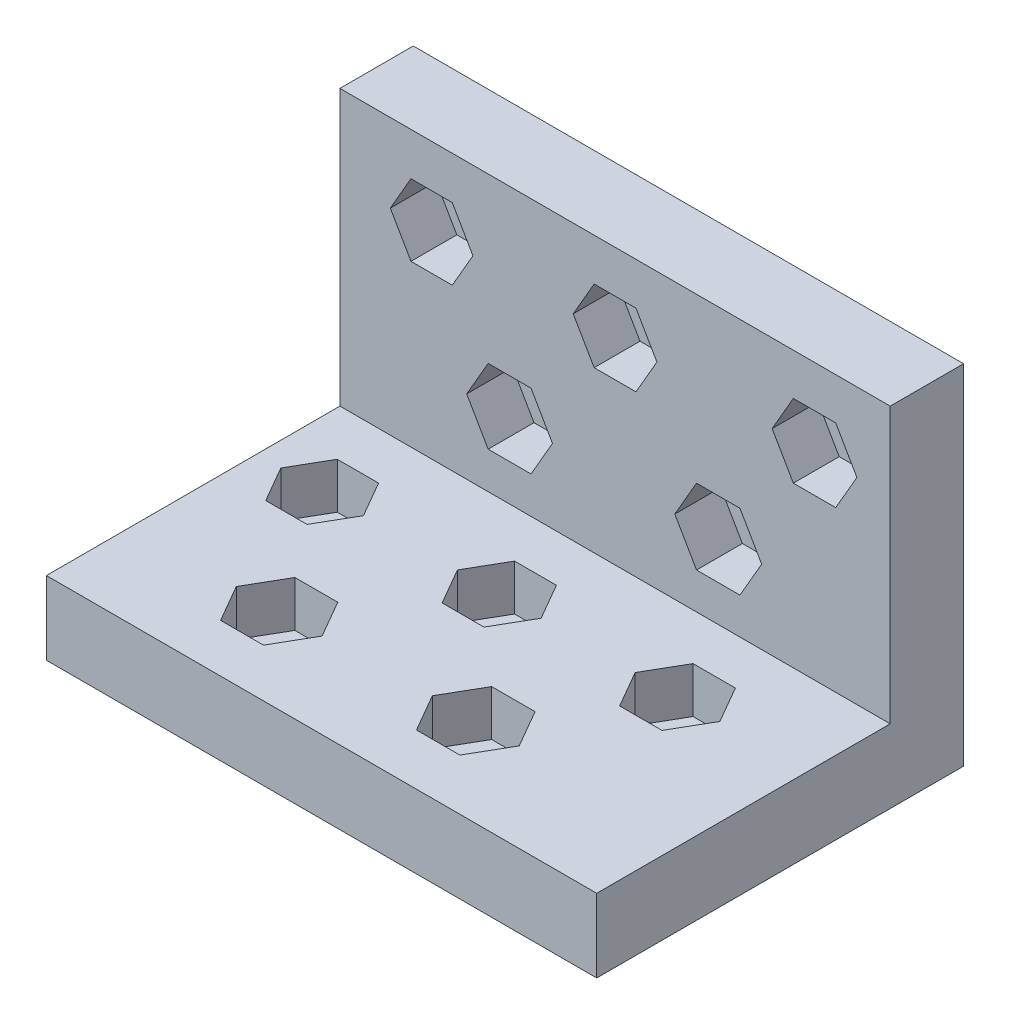
from build123d import *

# Parameters (mm, degrees)
SKETCH1_W               = 30
SKETCH1_H               = 20
BOSS_EXTRUDE1_DEPTH     = 4
SKETCH2_W               = 30
SKETCH2_H               = 4
BOSS_EXTRUDE2_DEPTH     = 15
CUT_EXTRUDE1_DEPTH      = 2.5
SKETCH4_R               = 1
CUT_EXTRUDE2_DEPTH      = 19.5
CUT_EXTRUDE2_DEPTH_BACK = 2.5
CUT_EXTRUDE3_DEPTH      = 16
CUT_EXTRUDE3_DEPTH_BACK = 2.5
SKETCH6_R               = 1
CUT_EXTRUDE4_DEPTH      = 18.5
CUT_EXTRUDE4_DEPTH_BACK = 2.5


with BuildPart() as part:
    # Sketch1 → Boss-Extrude1 (new body)
    with BuildSketch(Plane(origin=(0, 0, 0), x_dir=(1, 0, 0), z_dir=(0, 1, 0))):
        Rectangle(SKETCH1_W, SKETCH1_H)
    extrude(amount=BOSS_EXTRUDE1_DEPTH)

    # Sketch2 → Boss-Extrude2 (add)
    with BuildSketch(Plane(origin=(0, 4, 0), x_dir=(1, 0, 0), z_dir=(0, 1, 0))):
        with Locations((0, 8)):
            Rectangle(SKETCH2_W, SKETCH2_H)
    extrude(amount=BOSS_EXTRUDE2_DEPTH)

    # Sketch3 → Cut-Extrude1 (cut)
    with BuildSketch(Plane.XY.offset(-6)):
        Polygon((-8.874166975, 12.771236672), (-7.74833395, 14.721236672), (-8.874166975, 16.671236672), (-11.125833025, 16.671236672), (-12.25166605, 14.721236672), (-11.125833025, 12.771236672), align=None)
        Polygon((1.140266782, 12.743045001), (2.280533563, 14.718045001), (1.140266782, 16.693045001), (-1.140266782, 16.693045001), (-2.280533563, 14.718045001), (-1.140266782, 12.743045001), align=None)
        Polygon((12.028231439, 12.721236672), (13.182931977, 14.721236672), (12.028231439, 16.721236672), (9.718830362, 16.721236672), (8.564129823, 14.721236672), (9.718830362, 12.721236672), align=None)
        Polygon((-4.580088939, 6.006448413), (-3.410954644, 8.031448413), (-4.580088939, 10.056448413), (-6.91835753, 10.056448413), (-8.087491825, 8.031448413), (-6.91835753, 6.006448413), align=None)
        Polygon((6.807808173, 5.981448413), (7.991376224, 8.031448413), (6.807808173, 10.081448413), (4.440672069, 10.081448413), (3.257104017, 8.031448413), (4.440672069, 5.981448413), align=None)
    extrude(amount=-CUT_EXTRUDE1_DEPTH, mode=Mode.SUBTRACT)

    # Sketch4 → Cut-Extrude2 (cut, two sides)
    with BuildSketch(Plane.XY.offset(-8.5)) as cut_extrude2_sk:
        with Locations((-10, 14.721236672)):
            Circle(SKETCH4_R)
        with Locations((0, 14.718045001)):
            Circle(SKETCH4_R)
        with Locations((10.8735309, 14.721236672)):
            Circle(SKETCH4_R)
        with Locations((5.624240121, 8.031448413)):
            Circle(SKETCH4_R)
        with Locations((-5.749223235, 8.031448413)):
            Circle(SKETCH4_R)
    extrude(amount=CUT_EXTRUDE2_DEPTH, mode=Mode.SUBTRACT)
    extrude(cut_extrude2_sk.sketch, amount=-CUT_EXTRUDE2_DEPTH_BACK, mode=Mode.SUBTRACT)

    # Sketch5 → Cut-Extrude3 (cut, two sides)
    with BuildSketch(Plane(origin=(0, 4, 0), x_dir=(1, 0, 0), z_dir=(0, 1, 0))) as cut_extrude3_sk:
        Polygon((-10.310121887, -0.481448413), (-9.184288862, 1.468551587), (-10.310121887, 3.418551587), (-12.561787937, 3.418551587), (-13.687620962, 1.468551587), (-12.561787937, -0.481448413), align=None)
        Polygon((-0.64074259, -0.506448413), (0.499524192, 1.468551587), (-0.64074259, 3.443551587), (-2.921276153, 3.443551587), (-4.061542935, 1.468551587), (-2.921276153, -0.506448413), align=None)
        Polygon((9.091128264, -0.531448413), (10.245828803, 1.468551587), (9.091128264, 3.468551587), (6.781727188, 3.468551587), (5.627026649, 1.468551587), (6.781727188, -0.531448413), align=None)
        Polygon((-5.798674299, -7.368028115), (-4.629540004, -5.343028115), (-5.798674299, -3.318028115), (-8.136942889, -3.318028115), (-9.306077184, -5.343028115), (-8.136942889, -7.368028115), align=None)
        Polygon((4.745586795, -7.205553444), (5.929154847, -5.155553444), (4.745586795, -3.105553444), (2.378450691, -3.105553444), (1.194882639, -5.155553444), (2.378450691, -7.205553444), align=None)
    extrude(amount=CUT_EXTRUDE3_DEPTH, mode=Mode.SUBTRACT)
    extrude(cut_extrude3_sk.sketch, amount=-CUT_EXTRUDE3_DEPTH_BACK, mode=Mode.SUBTRACT)

    # Sketch6 → Cut-Extrude4 (cut, two sides)
    with BuildSketch(Plane(origin=(0, 1.5, 0), x_dir=(1, 0, 0), z_dir=(0, 1, 0))) as cut_extrude4_sk:
        with Locations((-11.435954912, 1.468551587)):
            Circle(SKETCH6_R)
        with Locations((-1.781009372, 1.468551587)):
            Circle(SKETCH6_R)
        with Locations((7.936427726, 1.468551587)):
            Circle(SKETCH6_R)
        with Locations((3.562018743, -5.155553444)):
            Circle(SKETCH6_R)
        with Locations((-6.967808594, -5.343028115)):
            Circle(SKETCH6_R)
    extrude(amount=CUT_EXTRUDE4_DEPTH, mode=Mode.SUBTRACT)
    extrude(cut_extrude4_sk.sketch, amount=-CUT_EXTRUDE4_DEPTH_BACK, mode=Mode.SUBTRACT)


solid = part.part
